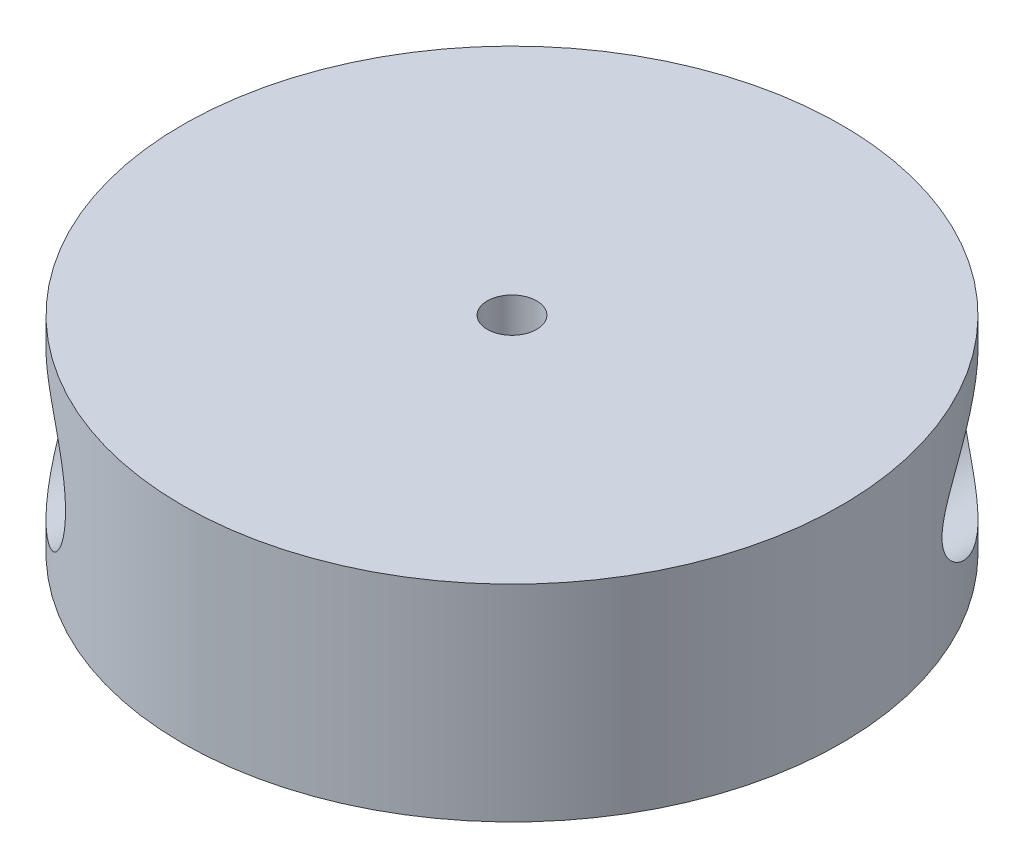
from build123d import *

# Parameters (mm, degrees)
SKETCH1_R           = 40
SKETCH1_R_2         = 3
BOSS_EXTRUDE1_DEPTH = 25
SKETCH2_R           = 7
SKETCH2_R_2         = 3
BOSS_EXTRUDE2_DEPTH = 15
SKETCH3_R           = 9
CUT_EXTRUDE1_DEPTH  = 41
SKETCH4_R           = 9
CUT_EXTRUDE2_DEPTH  = 41.0000001


with BuildPart() as part:
    # Sketch1 → Boss-Extrude1 (new body)
    with BuildSketch(Plane(origin=(0, 0, 0), x_dir=(1, 0, 0), z_dir=(0, 1, 0))):
        Circle(SKETCH1_R)
        Circle(SKETCH1_R_2, mode=Mode.SUBTRACT)
    extrude(amount=BOSS_EXTRUDE1_DEPTH)

    # Sketch2 → Boss-Extrude2 (add)
    with BuildSketch(Plane.XZ):
        Circle(SKETCH2_R)
        Circle(SKETCH2_R_2, mode=Mode.SUBTRACT)
    extrude(amount=BOSS_EXTRUDE2_DEPTH)

    # Sketch3 → Cut-Extrude1 (cut, through all)
    with BuildSketch(Plane.XY):
        with Locations((28, 12.5)):
            Circle(SKETCH3_R)
    extrude(amount=-CUT_EXTRUDE1_DEPTH, mode=Mode.SUBTRACT)

    # Sketch4 → Cut-Extrude2 (cut, through all)
    with BuildSketch(Plane.XY):
        with Locations((-28, 12.5)):
            Circle(SKETCH4_R)
    extrude(amount=CUT_EXTRUDE2_DEPTH, mode=Mode.SUBTRACT)


solid = part.part
